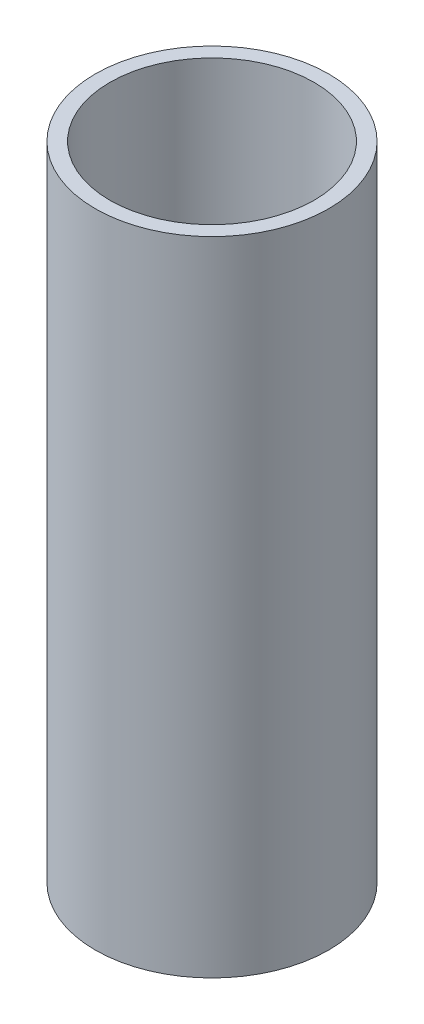
from build123d import *

# Parameters (mm, degrees)
ESQUISSE2_R        = 12
ESQUISSE2_R_2      = 10.5
BOSS_EXTRU_1_DEPTH = 33


with BuildPart() as part:
    # Esquisse2 → Boss.-Extru.1 (new body, symmetric)
    with BuildSketch(Plane(origin=(0, 0, 0), x_dir=(1, 0, 0), z_dir=(0, 1, 0))):
        Circle(ESQUISSE2_R)
        Circle(ESQUISSE2_R_2, mode=Mode.SUBTRACT)
    extrude(amount=BOSS_EXTRU_1_DEPTH, both=True)


solid = part.part
